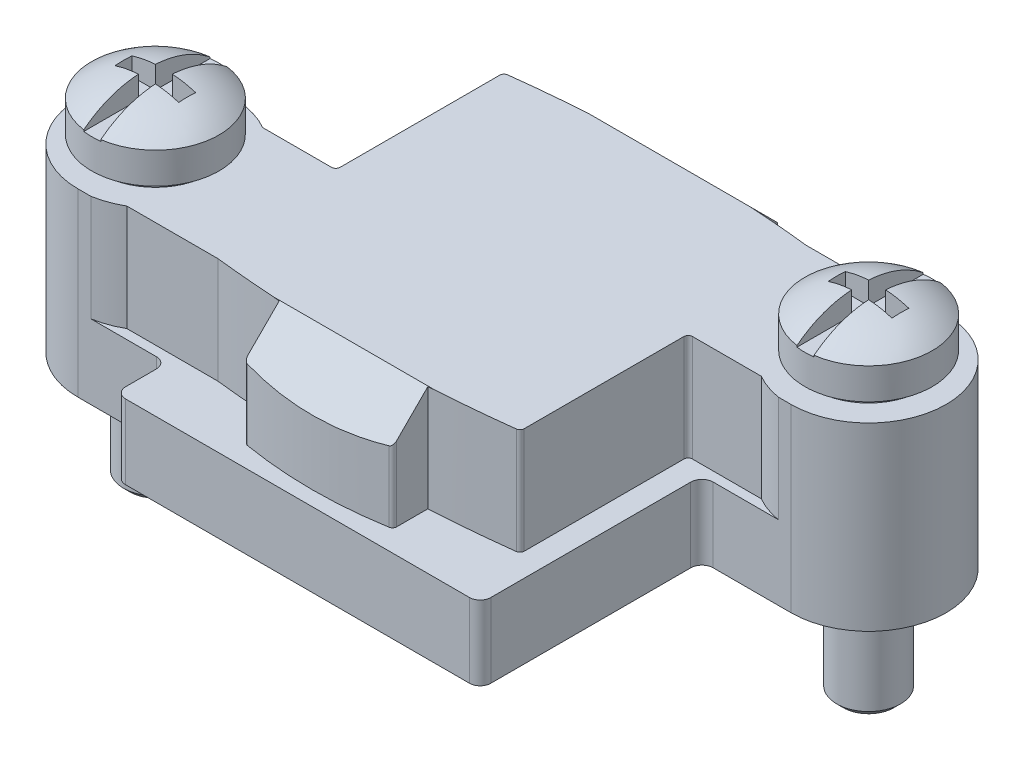
from build123d import *

# Parameters (mm, degrees)
BOSS_EXTRUDE1_DEPTH     = 8.5
SKETCH2_W               = 40.53674955
SKETCH2_H               = 32.519038644
CUT_EXTRUDE1_DEPTH      = 5
CUT_EXTRUDE2_DEPTH      = 5
CUT_EXTRUDE2_DEPTH_BACK = 5
CUT_EXTRUDE3_DEPTH      = 5
CUT_EXTRUDE3_DEPTH_BACK = 5
CUT_EXTRUDE4_DEPTH      = 5
CUT_EXTRUDE5_DEPTH      = 5


with BuildPart() as part:
    # Sketch1 → Boss-Extrude1 (new body)
    with BuildSketch(Plane(origin=(0, 0, 0), x_dir=(1, 0, 0), z_dir=(0, 1, 0))):
        with BuildLine():
            Line((-12.8, -7.65), (-9.1, -7.65))
            ThreePointArc((-9.1, -7.65), (-8.746446609, -7.796446609), (-8.6, -8.15))
            Line((-8.6, -8.15), (-8.6, -9.6))
            ThreePointArc((-8.6, -9.6), (-8.453553391, -9.953553391), (-8.1, -10.1))
            Line((-8.1, -10.1), (8.1, -10.1))
            ThreePointArc((8.1, -10.1), (8.453553391, -9.953553391), (8.6, -9.6))
            Line((8.6, -9.6), (8.6, -0.18))
            ThreePointArc((8.6, -0.18), (8.755233406, 0.194766594), (9.13, 0.35))
            Line((9.13, 0.35), (12.8, 0.35))
            ThreePointArc((12.8, 0.35), (16.45, 4), (12.8, 7.65))
            Line((12.8, 7.65), (9.1, 7.65))
            ThreePointArc((9.1, 7.65), (8.746446609, 7.796446609), (8.6, 8.15))
            Line((8.6, 8.15), (8.6, 9.6))
            ThreePointArc((8.6, 9.6), (8.453553391, 9.953553391), (8.1, 10.1))
            Line((8.1, 10.1), (-8.1, 10.1))
            ThreePointArc((-8.1, 10.1), (-8.453553391, 9.953553391), (-8.6, 9.6))
            Line((-8.6, 9.6), (-8.6, 0.15))
            ThreePointArc((-8.6, 0.15), (-8.746446609, -0.203553391), (-9.1, -0.35))
            Line((-9.1, -0.35), (-12.8, -0.35))
            ThreePointArc((-12.8, -0.35), (-16.45, -4), (-12.8, -7.65))
        make_face()
    extrude(amount=BOSS_EXTRUDE1_DEPTH)

    # Sketch2 → Cut-Extrude1 (cut)
    with BuildSketch(Plane(origin=(0, 8.5, 0), x_dir=(1, 0, 0), z_dir=(0, 1, 0))):
        with Locations((0.049799447, -1.045788379)):
            Rectangle(SKETCH2_W, SKETCH2_H)
        with BuildLine():
            Line((-10.942582438, -7.2), (-6.658387125, -7.2))
            ThreePointArc((-6.658387125, -7.2), (-5.080966469, -7.35507325), (-3.5, -7.468425178))
            Line((-3.5, -7.468425178), (-3.5, -8.931694617))
            ThreePointArc((-3.5, -8.931694617), (-3.452752523, -9.060794062), (-3.333333333, -9.128897276))
            ThreePointArc((-3.333333333, -9.128897276), (0, -9.408631332), (3.333333333, -9.128897276))
            ThreePointArc((3.333333333, -9.128897276), (3.452752523, -9.060794062), (3.5, -8.931694617))
            Line((3.5, -8.931694617), (3.5, -7.468425178))
            ThreePointArc((3.5, -7.468425178), (5.414980187, -7.325745819), (7.324413769, -7.12185882))
            ThreePointArc((7.324413769, -7.12185882), (7.449804462, -7.055863448), (7.5, -6.923354493))
            Line((7.5, -6.923354493), (7.5, 0.6))
            ThreePointArc((7.5, 0.6), (7.558578644, 0.741421356), (7.7, 0.8))
            Line((7.7, 0.8), (10.942582438, 0.8))
            ThreePointArc((10.942582438, 0.8), (16.5, 4), (10.942582438, 7.2))
            Line((10.942582438, 7.2), (6.658387125, 7.2))
            ThreePointArc((6.658387125, 7.2), (5.080966469, 7.35507325), (3.5, 7.468425178))
            Line((3.5, 7.468425178), (3.5, 8.931694617))
            ThreePointArc((3.5, 8.931694617), (3.452752508, 9.060794079), (3.333333288, 9.128897284))
            ThreePointArc((3.333333288, 9.128897284), (-2.3e-08, 9.408631332), (-3.333333333, 9.128897276))
            ThreePointArc((-3.333333333, 9.128897276), (-3.452752523, 9.060794062), (-3.5, 8.931694617))
            Line((-3.5, 8.931694617), (-3.5, 7.468425178))
            ThreePointArc((-3.5, 7.468425178), (-5.414980187, 7.325745819), (-7.324413769, 7.12185882))
            ThreePointArc((-7.324413769, 7.12185882), (-7.449804462, 7.055863448), (-7.5, 6.923354493))
            Line((-7.5, 6.923354493), (-7.5, -0.6))
            ThreePointArc((-7.5, -0.6), (-7.558578644, -0.741421356), (-7.7, -0.8))
            Line((-7.7, -0.8), (-10.942582438, -0.8))
            ThreePointArc((-10.942582438, -0.8), (-16.5, -4), (-10.942582438, -7.2))
        make_face(mode=Mode.SUBTRACT)
    extrude(amount=-CUT_EXTRUDE1_DEPTH, mode=Mode.SUBTRACT)

    # Sketch3 → Cut-Extrude2 (cut, two sides)
    with BuildSketch(Plane(origin=(0, 0, 0), x_dir=(0, 0, -1), z_dir=(1, 0, 0))) as cut_extrude2_sk:
        Polygon((7.45, 8.5), (9.45, 6.5), (9.45, 8.5), align=None)
    extrude(amount=CUT_EXTRUDE2_DEPTH, mode=Mode.SUBTRACT)
    extrude(cut_extrude2_sk.sketch, amount=-CUT_EXTRUDE2_DEPTH_BACK, mode=Mode.SUBTRACT)

    # Sketch4 → Cut-Extrude3 (cut, two sides)
    with BuildSketch(Plane(origin=(0, 0, 0), x_dir=(0, 0, -1), z_dir=(1, 0, 0))) as cut_extrude3_sk:
        Polygon((-9.45, 6.5), (-7.45, 8.5), (-9.45, 8.5), align=None)
    extrude(amount=CUT_EXTRUDE3_DEPTH, mode=Mode.SUBTRACT)
    extrude(cut_extrude3_sk.sketch, amount=-CUT_EXTRUDE3_DEPTH_BACK, mode=Mode.SUBTRACT)

    # Sketch5 → Revolve1 (revolve)
    with BuildSketch(Plane.XY.offset(4)):
        with BuildLine():
            Line((-12.8, 8.5), (-15.3, 8.5))
            ThreePointArc((-15.3, 8.5), (-15.182842712, 8.782842712), (-14.9, 8.9))
            Line((-14.9, 8.9), (-12.8, 8.9))
            Line((-12.8, 8.9), (-12.8, 8.5))
        make_face()
    revolve(axis=Axis((-12.8, 8.9, 4), (0, -1, 0)))

    # Sketch6 → Revolve2 (revolve)
    with BuildSketch(Plane.XY.offset(-4)):
        with BuildLine():
            Line((12.8, 8.5), (10.3, 8.5))
            ThreePointArc((10.3, 8.5), (10.417157288, 8.782842712), (10.7, 8.9))
            Line((10.7, 8.9), (12.8, 8.9))
            Line((12.8, 8.9), (12.8, 8.5))
        make_face()
    revolve(axis=Axis((12.8, 8.9, -4), (0, -1, 0)))

    # Sketch7 → Cut-Revolve1 (revolve, cut)
    with BuildSketch(Plane.XY.offset(4)):
        with BuildLine():
            Line((-12.8, 0), (-14.3, 0))
            Line((-14.3, 0), (-14.3, 4.125))
            Line((-14.3, 4.125), (-14.175, 4.25))
            Line((-14.175, 4.25), (-14.3, 4.375))
            Line((-14.3, 4.375), (-14.3, 8.5))
            ThreePointArc((-14.3, 8.5), (-14.417157288, 8.782842712), (-14.7, 8.9))
            Line((-14.7, 8.9), (-12.8, 8.9))
            Line((-12.8, 8.9), (-12.8, 0))
        make_face()
    revolve(axis=Axis((-12.8, 8.9, 4), (0, -1, 0)), mode=Mode.SUBTRACT)

    # Sketch8 → Cut-Revolve2 (revolve, cut)
    with BuildSketch(Plane.XY.offset(-4)):
        with BuildLine():
            Line((12.8, 0), (11.3, 0))
            Line((11.3, 0), (11.3, 4.125))
            Line((11.3, 4.125), (11.425, 4.25))
            Line((11.425, 4.25), (11.3, 4.375))
            Line((11.3, 4.375), (11.3, 8.5))
            ThreePointArc((11.3, 8.5), (11.182842712, 8.782842712), (10.9, 8.9))
            Line((10.9, 8.9), (12.8, 8.9))
            Line((12.8, 8.9), (12.8, 0))
        make_face()
    revolve(axis=Axis((12.8, 8.9, -4), (0, -1, 0)), mode=Mode.SUBTRACT)

    # Sketch9 → Revolve3 (revolve)
    with BuildSketch(Plane.XY.offset(4)):
        with BuildLine():
            Line((-12.8, -5.1), (-13.9935, -5.1))
            Line((-13.9935, -5.1), (-14.3, -4.7935))
            Line((-14.3, -4.7935), (-14.3, 8.9))
            Line((-14.3, 8.9), (-15.8, 8.9))
            Line((-15.8, 8.9), (-15.8, 10.37))
            ThreePointArc((-15.8, 10.37), (-14.388759249, 11.136277748), (-12.8, 11.37))
            Line((-12.8, 11.37), (-12.8, -5.1))
        make_face()
    revolve(axis=Axis((-12.8, 11.37, 4), (0, -1, 0)))

    # Sketch10 → Revolve4 (revolve)
    with BuildSketch(Plane.XY.offset(-4)):
        with BuildLine():
            Line((12.8, -5.1), (11.6065, -5.1))
            Line((11.6065, -5.1), (11.3, -4.7935))
            Line((11.3, -4.7935), (11.3, 8.9))
            Line((11.3, 8.9), (9.8, 8.9))
            Line((9.8, 8.9), (9.8, 10.37))
            ThreePointArc((9.8, 10.37), (11.211240751, 11.136277748), (12.8, 11.37))
            Line((12.8, 11.37), (12.8, -5.1))
        make_face()
    revolve(axis=Axis((12.8, 11.37, -4), (0, -1, 0)))

    # Sketch11 → Cut-Extrude4 (cut)
    with BuildSketch(Plane(origin=(0, 10.3, 0), x_dir=(1, 0, 0), z_dir=(0, 1, 0))):
        Polygon((11.3, 3.6), (12.4, 3.6), (12.4, 1), (13.2, 1), (13.2, 3.6), (14.3, 3.6), (14.3, 4.4), (13.2, 4.4), (13.2, 7), (12.4, 7), (12.4, 4.4), (11.3, 4.4), align=None)
    extrude(amount=CUT_EXTRUDE4_DEPTH, mode=Mode.SUBTRACT)

    # Sketch12 → Cut-Extrude5 (cut)
    with BuildSketch(Plane(origin=(0, 10.3, 0), x_dir=(1, 0, 0), z_dir=(0, 1, 0))):
        Polygon((-14.3, -4.4), (-13.2, -4.4), (-13.2, -7), (-12.4, -7), (-12.4, -4.4), (-11.3, -4.4), (-11.3, -3.6), (-12.4, -3.6), (-12.4, -1), (-13.2, -1), (-13.2, -3.6), (-14.3, -3.6), align=None)
    extrude(amount=CUT_EXTRUDE5_DEPTH, mode=Mode.SUBTRACT)


solid = part.part
